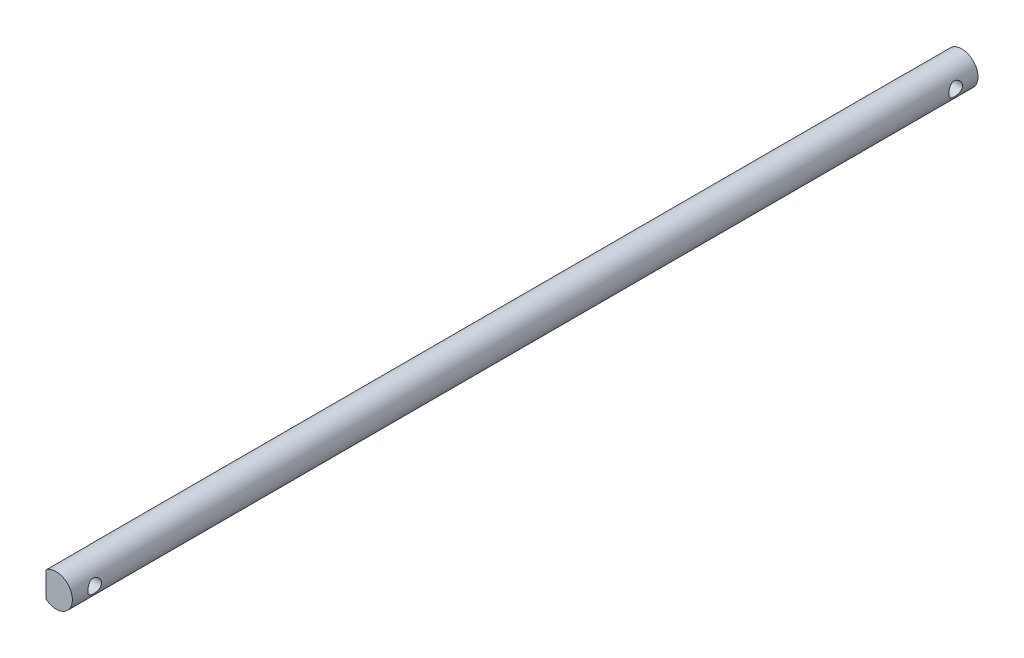
from build123d import *

# Parameters (mm, degrees)
CROQUIS1_R                   = 4
SALIENTE_EXTRUIR1_DEPTH      = 223
CORTAR_EXTRUIR1_DEPTH        = 11
TALADRO_DE_MARGEN_PARA_M31_D = 3.4


with BuildPart() as part:
    # Croquis1 → Saliente-Extruir1 (new body)
    with BuildSketch(Plane.XY):
        Circle(CROQUIS1_R)
    extrude(amount=SALIENTE_EXTRUIR1_DEPTH)

    # Croquis2 → Cortar-Extruir1 (cut)
    with BuildSketch(Plane.XY.offset(223)):
        with BuildLine():
            Line((-2.5, -3.122498999), (-2.5, 3.122498999))
            ThreePointArc((-2.5, 3.122498999), (-4, 0), (-2.5, -3.122498999))
        make_face()
    cortar_extruir1 = extrude(amount=-CORTAR_EXTRUIR1_DEPTH, mode=Mode.SUBTRACT)

    # Simetría1: Cortar-Extruir1 across plane
    add(cortar_extruir1.mirror(Plane.XY.offset(111.5)), mode=Mode.SUBTRACT)

    # Taladro de margen para M31 (through all)
    with Locations(Plane(origin=(-2.5, 0, 217.5), x_dir=(0, 0, -1), z_dir=(-1, 0, 0))):
        with Locations((0, 0)):
            taladro_de_margen_para_m31 = Hole(TALADRO_DE_MARGEN_PARA_M31_D / 2)

    # Simetría3: Taladro de margen para M31 across plane
    add(taladro_de_margen_para_m31.mirror(Plane.XY.offset(111.5)), mode=Mode.SUBTRACT)


solid = part.part
